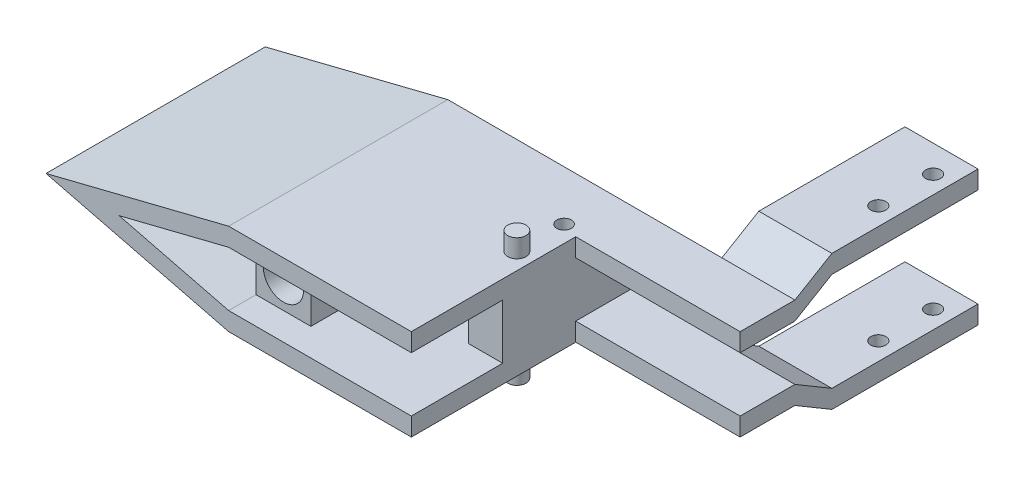
from build123d import *

# Parameters (mm, degrees)
BOSS_EXTRU_1_DEPTH      = 60
BOSS_EXTRU_2_START      = 2.5
ESQUISSE3_W             = 15
ESQUISSE3_H             = 15
BOSS_EXTRU_2_DEPTH      = 50
ENL_V_START             = -10
ESQUISSE4_R             = 5.5
ENL_V_MAT_EXTRU_1_DEPTH = 105
ESQUISSE5_W             = 9.327942275
ESQUISSE5_H             = 15
BOSS_EXTRU_3_DEPTH      = 35
ESQUISSE12_W            = 95
ESQUISSE12_H            = 15
BOSS_EXTRU_9_DEPTH      = 5
ESQUISSE13_W            = 95
ESQUISSE13_H            = 15
BOSS_EXTRU_10_DEPTH     = 5
BOSS_EXTRU_12_DEPTH     = 20
ESQUISSE18_R            = 2.05
ENL_V_MAT_EXTRU_4_DEPTH = 50
ESQUISSE20_R            = 2
ENL_V_MAT_EXTRU_6_DEPTH = 32
BOSS_EXTRU_13_START     = 5
ESQUISSE21_R            = 2.5
BOSS_EXTRU_13_DEPTH     = 35


with BuildPart() as part:
    # Esquisse1 → Boss.-Extru.1 (new body)
    with BuildSketch(Plane.XY):
        Polygon((-29.816132576, -5), (20.183867424, -5), (20.183867424, 0), (-29.816132576, 0), (-79.816132576, -12.5), (-29.816132576, -25), (20.183867424, -25), (20.183867424, -20), (-29.816132576, -20), (-59.816132576, -12.5), align=None)
    extrude(amount=BOSS_EXTRU_1_DEPTH)

    # Esquisse3 → Boss.-Extru.2 (add)
    with BuildSketch(Plane.XY.offset(BOSS_EXTRU_2_START)):
        with Locations((-22.316132576, -12.5)):
            Rectangle(ESQUISSE3_W, ESQUISSE3_H)
    extrude(amount=BOSS_EXTRU_2_DEPTH)

    # Esquisse4 → Enlèv. mat.-Extru.1 (cut)
    with BuildSketch(Plane.XY.offset(ENL_V_START)):
        with Locations((-22.316132576, -12.5)):
            Circle(ESQUISSE4_R)
    extrude(amount=ENL_V_MAT_EXTRU_1_DEPTH, mode=Mode.SUBTRACT)

    # Esquisse5 → Boss.-Extru.3 (add)
    with BuildSketch(Plane.XY):
        with Locations((15.519896287, -12.5)):
            Rectangle(ESQUISSE5_W, ESQUISSE5_H)
    extrude(amount=BOSS_EXTRU_3_DEPTH)

    # Esquisse12 → Boss.-Extru.9 (add)
    with BuildSketch(Plane(origin=(0, 0, 0), x_dir=(1, 0, 0), z_dir=(0, 1, 0))):
        with Locations((17.683867424, -7.5)):
            Rectangle(ESQUISSE12_W, ESQUISSE12_H)
    extrude(amount=-BOSS_EXTRU_9_DEPTH)

    # Esquisse13 → Boss.-Extru.10 (add)
    with BuildSketch(Plane(origin=(0, -25, 0), x_dir=(-1, 0, 0), z_dir=(0, -1, 0))):
        with Locations((-17.683867424, -7.5)):
            Rectangle(ESQUISSE13_W, ESQUISSE13_H)
    extrude(amount=-BOSS_EXTRU_10_DEPTH)

    # Esquisse14 → Boss.-Extru.12 (add)
    with BuildSketch(Plane(origin=(65.183867424, 0, 0), x_dir=(0, 0, -1), z_dir=(1, 0, 0))):
        Polygon((0, 0), (-15, 0), (-15, -5), (0, -5), (10.113760869, 1), (50.113760869, 1), (50.113760869, 6), (10.113760869, 6), align=None)
        Polygon((-15, -25), (-15, -20), (0, -20), (10.113760869, -26), (50.113760869, -26), (50.113760869, -31), (10.113760869, -31), (0, -25), align=None)
    extrude(amount=-BOSS_EXTRU_12_DEPTH)

    # Esquisse18 → Enlèv. mat.-Extru.4 (cut)
    with BuildSketch(Plane(origin=(0, 6, 0), x_dir=(1, 0, 0), z_dir=(0, 1, 0))):
        with Locations(Location((60.269613545, 42.737284556, 0), (0, 0, 270))):  # turned: the seam where the file's is
            Circle(ESQUISSE18_R)
        with Locations(Location((60.269613545, 27.737284556, 0), (0, 0, 270))):  # turned: the seam where the file's is
            Circle(ESQUISSE18_R)
    extrude(amount=-ENL_V_MAT_EXTRU_4_DEPTH, mode=Mode.SUBTRACT)

    # Esquisse20 → Enlèv. mat.-Extru.6 (cut, through all)
    with BuildSketch(Plane(origin=(0, -25, 0), x_dir=(-1, 0, 0), z_dir=(0, -1, 0))):
        with Locations(Location((-15.612089386, -13.621364953, 0), (0, 0, 90))):  # turned: the seam where the file's is
            Circle(ESQUISSE20_R)
    extrude(amount=-ENL_V_MAT_EXTRU_6_DEPTH, mode=Mode.SUBTRACT)

    # Esquisse21 → Boss.-Extru.13 (add)
    with BuildSketch(Plane(origin=(0, -25, 0), x_dir=(-1, 0, 0), z_dir=(0, -1, 0)).offset(BOSS_EXTRU_13_START)):
        with Locations(Location((-15.612089386, -26.534383987, 0), (0, 0, 90))):  # turned: the seam where the file's is
            Circle(ESQUISSE21_R)
    extrude(amount=-BOSS_EXTRU_13_DEPTH)


solid = part.part
